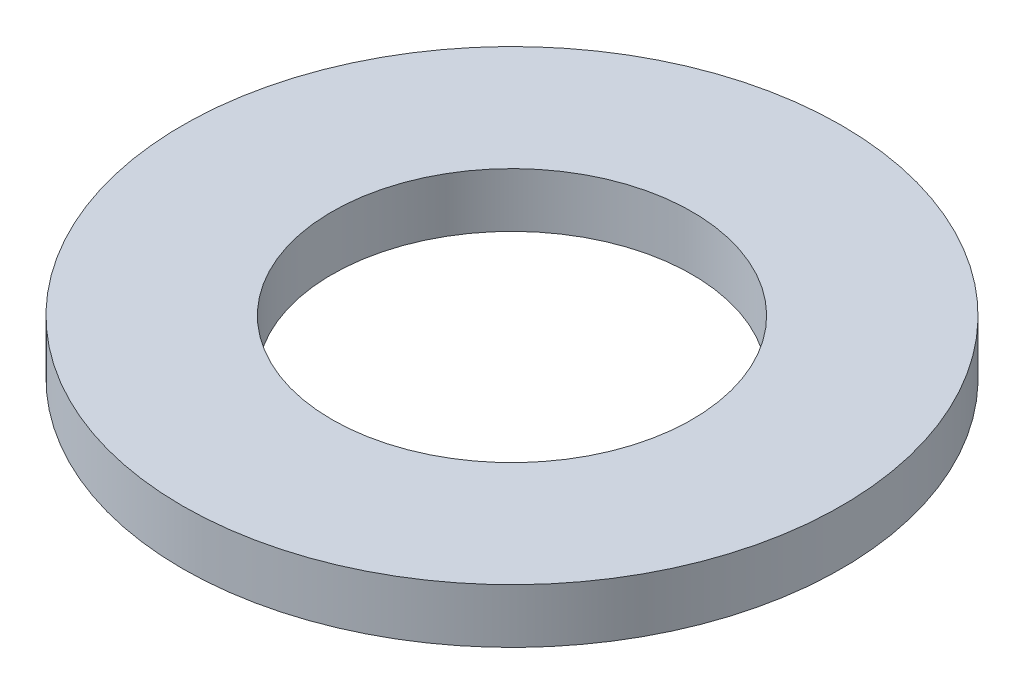
from build123d import *

# Parameters (mm, degrees)
SKETCH1_R           = 4.85
SKETCH1_R_2         = 2.65
BOSS_EXTRUDE1_DEPTH = 0.8


with BuildPart() as part:
    # Sketch1 → Boss-Extrude1 (new body)
    with BuildSketch(Plane(origin=(0, 0, 0), x_dir=(1, 0, 0), z_dir=(0, 1, 0))):
        Circle(SKETCH1_R)
        Circle(SKETCH1_R_2, mode=Mode.SUBTRACT)
    extrude(amount=BOSS_EXTRUDE1_DEPTH)


solid = part.part
